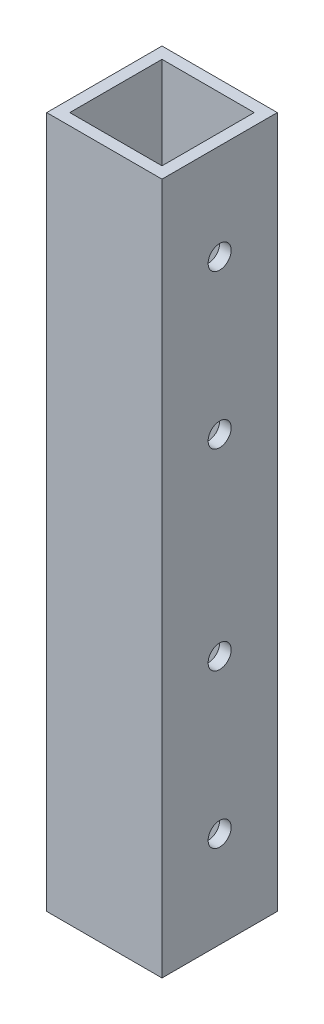
from build123d import *

# Parameters (mm, degrees)
SKETCH1_W           = 15
SKETCH1_H           = 15
SKETCH1_W_2         = 12
SKETCH1_H_2         = 12
EXTRUDE_THIN1_DEPTH = 90
SKETCH2_R           = 1.5
CUT_EXTRUDE1_DEPTH  = 16


with BuildPart() as part:
    # Sketch1 → Extrude-Thin1 (new body)
    with BuildSketch(Plane(origin=(0, 0, 0), x_dir=(1, 0, 0), z_dir=(0, 1, 0))):
        with Locations((7.5, 7.5)):
            Rectangle(SKETCH1_W, SKETCH1_H)
        with Locations((7.5, 7.5)):
            Rectangle(SKETCH1_W_2, SKETCH1_H_2, mode=Mode.SUBTRACT)
    extrude(amount=EXTRUDE_THIN1_DEPTH)

    # Sketch2 → Cut-Extrude1 (cut, through all)
    with BuildSketch(Plane(origin=(15, 0, 0), x_dir=(0, 0, -1), z_dir=(1, 0, 0))):
        with Locations((7.5, 12.5)):
            Circle(SKETCH2_R)
        with Locations((7.5, 32.5)):
            Circle(SKETCH2_R)
        with Locations((7.5, 57.5)):
            Circle(SKETCH2_R)
        with Locations((7.5, 77.5)):
            Circle(SKETCH2_R)
    extrude(amount=-CUT_EXTRUDE1_DEPTH, mode=Mode.SUBTRACT)


solid = part.part
